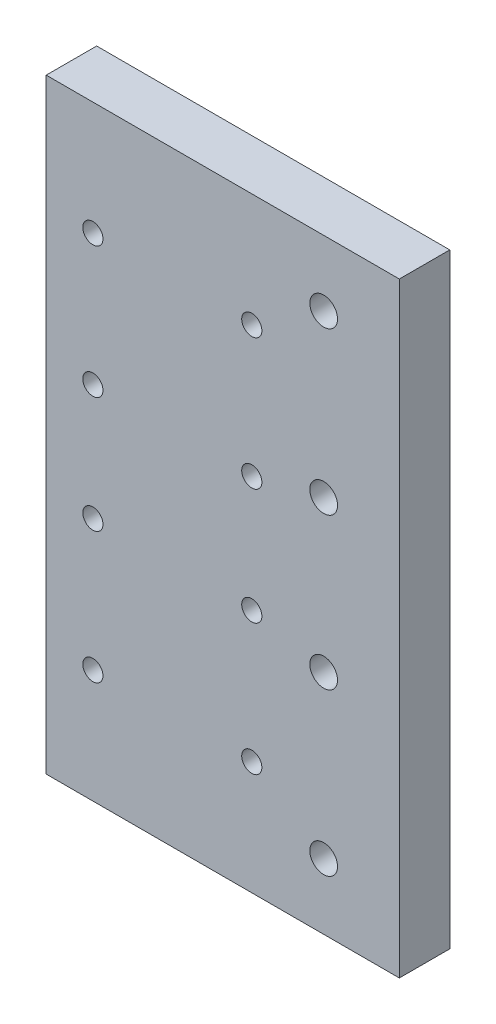
from build123d import *

# Parameters (mm, degrees)
SKETCH1_W           = 70
SKETCH1_H           = 120
SKETCH1_R           = 2
SKETCH1_R_2         = 2.75
BOSS_EXTRUDE1_DEPTH = 10


with BuildPart() as part:
    # Sketch1 → Boss-Extrude1 (new body)
    with BuildSketch(Plane.XY):
        with Locations((-35, 0)):
            Rectangle(SKETCH1_W, SKETCH1_H)
        with Locations((-60.75, 37.5)):
            Circle(SKETCH1_R, mode=Mode.SUBTRACT)
        with Locations((-29.25, 37.5)):
            Circle(SKETCH1_R, mode=Mode.SUBTRACT)
        with Locations((-60.75, 11.5)):
            Circle(SKETCH1_R, mode=Mode.SUBTRACT)
        with Locations((-29.25, 11.5)):
            Circle(SKETCH1_R, mode=Mode.SUBTRACT)
        with Locations((-60.75, -11.5)):
            Circle(SKETCH1_R, mode=Mode.SUBTRACT)
        with Locations((-29.25, -11.5)):
            Circle(SKETCH1_R, mode=Mode.SUBTRACT)
        with Locations((-29.25, -37.5)):
            Circle(SKETCH1_R, mode=Mode.SUBTRACT)
        with Locations((-60.75, -37.5)):
            Circle(SKETCH1_R, mode=Mode.SUBTRACT)
        with Locations((-15, 47)):
            Circle(SKETCH1_R_2, mode=Mode.SUBTRACT)
        with Locations((-15, 15)):
            Circle(SKETCH1_R_2, mode=Mode.SUBTRACT)
        with Locations((-15, -15)):
            Circle(SKETCH1_R_2, mode=Mode.SUBTRACT)
        with Locations((-15, -47)):
            Circle(SKETCH1_R_2, mode=Mode.SUBTRACT)
    extrude(amount=BOSS_EXTRUDE1_DEPTH)


solid = part.part
